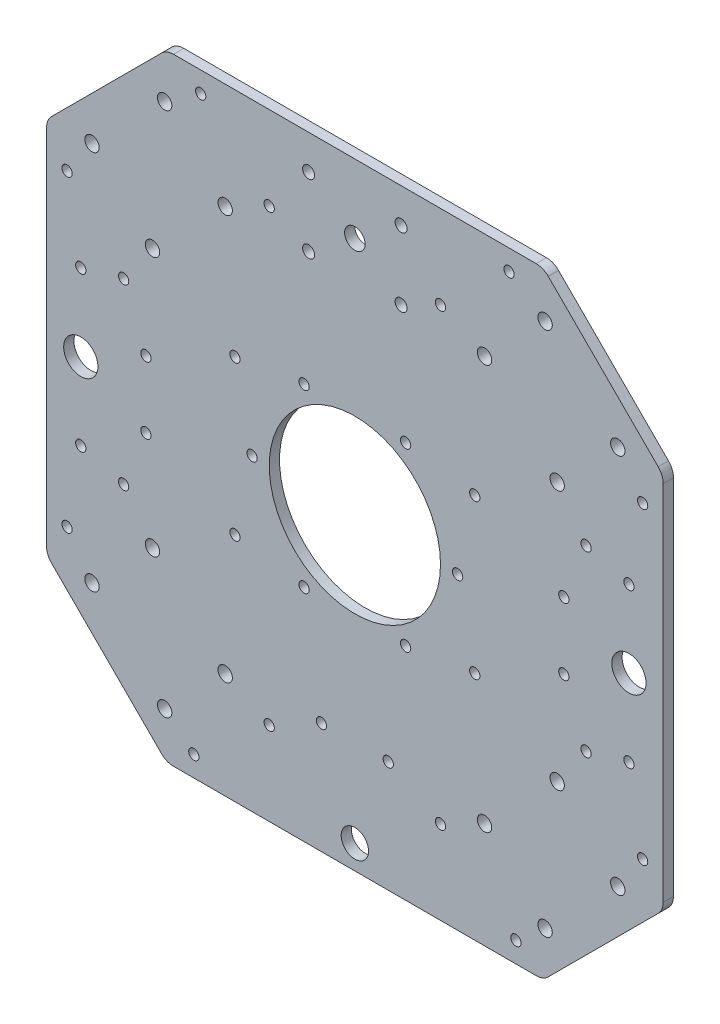
from build123d import *

# Parameters (mm, degrees)
SKETCH_1_W           = 180
SKETCH_1_H           = 180
EXTRUDE_1_DEPTH      = 3
CUT_EXTRUDE_1_DEPTH  = 3
SKETCH_3_R           = 2.1
CUT_EXTRUDE_2_DEPTH  = 3
SKETCH_4_R           = 25
SKETCH_4_R_2         = 1.5
CUT_EXTRUDE_3_DEPTH  = 3
SKETCH_5_R           = 1.5
SKETCH_5_R_2         = 5
CUT_EXTRUDE_4_DEPTH  = 3
SKETCH_6_R           = 1.5
CUT_EXTRUDE_5_DEPTH  = 3
FILLET_2_R           = 5
SKETCH_7_R           = 1.5
CUT_EXTRUDE_6_DEPTH  = 3
SKETCH_8_R           = 1.5
CUT_EXTRUDE_7_DEPTH  = 3
SKETCH_10_R          = 1.5
CUT_EXTRUDE_9_DEPTH  = 3
SKETCH_11_R          = 1.5
SKETCH_11_R_2        = 4
CUT_EXTRUDE_10_DEPTH = 3
SKETCH_12_R          = 3
CUT_EXTRUDE_11_DEPTH = 3
SKETCH_13_R          = 1.75
CUT_EXTRUDE_12_DEPTH = 3


with BuildPart() as part:
    # 草图1 → 凸台-拉伸1 (new body)
    with BuildSketch(Plane.XY):
        Rectangle(SKETCH_1_W, SKETCH_1_H)
    extrude(amount=EXTRUDE_1_DEPTH)

    # 草图2 → 切除-拉伸1 (cut)
    with BuildSketch(Plane.XY.offset(3)):
        Polygon((-90, 90), (-55, 90), (-90, 55), align=None)
        Polygon((90, 90), (55, 90), (90, 55), align=None)
        Polygon((-90, -90), (-90, -55), (-55, -90), align=None)
        Polygon((90, -90), (90, -55), (55, -90), align=None)
    extrude(amount=-CUT_EXTRUDE_1_DEPTH, mode=Mode.SUBTRACT)

    # 草图3 → 切除-拉伸2 (cut)
    with BuildSketch(Plane.XY.offset(3)):
        with Locations((55.529437252, 76.742640687)):
            Circle(SKETCH_3_R)
        with Locations((76.742640687, 55.529437252)):
            Circle(SKETCH_3_R)
        with Locations((59.064971157, 37.851767722)):
            Circle(SKETCH_3_R)
        with Locations((37.851767722, 59.064971157)):
            Circle(SKETCH_3_R)
        with Locations((-55.529437252, 76.742640687)):
            Circle(SKETCH_3_R)
        with Locations((-37.851767722, 59.064971157)):
            Circle(SKETCH_3_R)
        with Locations((-59.064971157, 37.851767722)):
            Circle(SKETCH_3_R)
        with Locations((-76.742640687, 55.529437252)):
            Circle(SKETCH_3_R)
        with Locations((-59.064971157, -37.851767722)):
            Circle(SKETCH_3_R)
        with Locations((-76.742640687, -55.529437252)):
            Circle(SKETCH_3_R)
        with Locations((-37.851767722, -59.064971157)):
            Circle(SKETCH_3_R)
        with Locations((-55.529437252, -76.742640687)):
            Circle(SKETCH_3_R)
        with Locations((76.742640687, -55.529437252)):
            Circle(SKETCH_3_R)
        with Locations((55.529437252, -76.742640687)):
            Circle(SKETCH_3_R)
        with Locations((37.851767722, -59.064971157)):
            Circle(SKETCH_3_R)
        with Locations((59.064971157, -37.851767722)):
            Circle(SKETCH_3_R)
    extrude(amount=-CUT_EXTRUDE_2_DEPTH, mode=Mode.SUBTRACT)

    # 草图4 → 切除-拉伸3 (cut)
    with BuildSketch(Plane.XY.offset(3)):
        Circle(SKETCH_4_R)
        with Locations((67.5, 26)):
            Circle(SKETCH_4_R_2)
        with Locations((67.5, -26)):
            Circle(SKETCH_4_R_2)
        with Locations((-67.5, -26)):
            Circle(SKETCH_4_R_2)
        with Locations((-67.5, 26)):
            Circle(SKETCH_4_R_2)
    extrude(amount=-CUT_EXTRUDE_3_DEPTH, mode=Mode.SUBTRACT)

    # 草图5 → 切除-拉伸4 (cut)
    with BuildSketch(Plane.XY.offset(3)):
        with Locations((61, 9.75)):
            Circle(SKETCH_5_R)
        with Locations((61, -9.75)):
            Circle(SKETCH_5_R)
        with Locations((80, 0)):
            Circle(SKETCH_5_R_2)
        with Locations((35, 22.5)):
            Circle(SKETCH_5_R)
        with Locations((35, -22.5)):
            Circle(SKETCH_5_R)
        with Locations((80, -22.5)):
            Circle(SKETCH_5_R)
        with Locations((80, 22.5)):
            Circle(SKETCH_5_R)
        with Locations((-80, 22.5)):
            Circle(SKETCH_5_R)
        with Locations((-80, -22.5)):
            Circle(SKETCH_5_R)
        with Locations((-35, -22.5)):
            Circle(SKETCH_5_R)
        with Locations((-35, 22.5)):
            Circle(SKETCH_5_R)
        with Locations((-61, 9.75)):
            Circle(SKETCH_5_R)
        with Locations((-61, -9.75)):
            Circle(SKETCH_5_R)
        with Locations((-80, 0)):
            Circle(SKETCH_5_R_2)
    extrude(amount=-CUT_EXTRUDE_4_DEPTH, mode=Mode.SUBTRACT)

    # 草图6 → 切除-拉伸5 (cut)
    with BuildSketch(Plane.XY.offset(3)):
        with Locations((14.820508076, 25.669872981)):
            Circle(SKETCH_6_R)
        with Locations((-14.820508076, 25.669872981)):
            Circle(SKETCH_6_R)
        with Locations((-30, 0)):
            Circle(SKETCH_6_R)
        with Locations((-14.820508076, -25.669872981)):
            Circle(SKETCH_6_R)
        with Locations((14.820508076, -25.669872981)):
            Circle(SKETCH_6_R)
        with Locations((30, 0)):
            Circle(SKETCH_6_R)
    extrude(amount=-CUT_EXTRUDE_5_DEPTH, mode=Mode.SUBTRACT)

    # 圆角2
    fillet_2_edges = [part.edges().sort_by_distance(p)[0] for p in [
        (90, 55, 1.5),
        (55, 90, 1.5),
        (-55, -90, 1.5),
        (-90, -55, 1.5),
        (55, -90, 1.5),
        (90, -55, 1.5),
        (-90, 55, 1.5),
        (-55, 90, 1.5),
    ]]
    fillet(fillet_2_edges, radius=FILLET_2_R)

    # 草图7 → 切除-拉伸6 (cut)
    with BuildSketch(Plane.XY.offset(3)):
        with Locations((-25, 65.6)):
            Circle(SKETCH_7_R)
        with Locations((25, 65.6)):
            Circle(SKETCH_7_R)
    extrude(amount=-CUT_EXTRUDE_6_DEPTH, mode=Mode.SUBTRACT)

    # 草图8 → 切除-拉伸7 (cut)
    with BuildSketch(Plane.XY.offset(3)):
        with Locations((25, -65.6)):
            Circle(SKETCH_8_R)
        with Locations((-25, -65.6)):
            Circle(SKETCH_8_R)
    extrude(amount=-CUT_EXTRUDE_7_DEPTH, mode=Mode.SUBTRACT)

    # 草图10 → 切除-拉伸9 (cut)
    with BuildSketch(Plane.XY.offset(3)):
        with Locations((-47, -84)):
            Circle(SKETCH_10_R)
        with Locations((47, -84)):
            Circle(SKETCH_10_R)
        with Locations((-84, -45)):
            Circle(SKETCH_10_R)
        with Locations((-84, 45)):
            Circle(SKETCH_10_R)
        with Locations((84, -45)):
            Circle(SKETCH_10_R)
        with Locations((84, 45)):
            Circle(SKETCH_10_R)
        with Locations((-45, 84)):
            Circle(SKETCH_10_R)
        with Locations((45, 84)):
            Circle(SKETCH_10_R)
    extrude(amount=-CUT_EXTRUDE_9_DEPTH, mode=Mode.SUBTRACT)

    # 草图11 → 切除-拉伸10 (cut)
    with BuildSketch(Plane.XY.offset(3)):
        with Locations((9.75, -57.5)):
            Circle(SKETCH_11_R)
        with Locations((-9.75, -57.5)):
            Circle(SKETCH_11_R)
        with Locations((0, -83)):
            Circle(SKETCH_11_R_2)
    extrude(amount=-CUT_EXTRUDE_10_DEPTH, mode=Mode.SUBTRACT)

    # 草图12 → 切除-拉伸11 (cut)
    with BuildSketch(Plane.XY.offset(3)):
        with Locations((0, 69.9)):
            Circle(SKETCH_12_R)
    extrude(amount=-CUT_EXTRUDE_11_DEPTH, mode=Mode.SUBTRACT)

    # 草图13 → 切除-拉伸12 (cut)
    with BuildSketch(Plane.XY.offset(3)):
        with Locations((-13.5, 79.940916293)):
            Circle(SKETCH_13_R)
        with Locations((-13.5, 59.859083707)):
            Circle(SKETCH_13_R)
        with Locations((13.5, 59.859083707)):
            Circle(SKETCH_13_R)
        with Locations((13.5, 79.940916293)):
            Circle(SKETCH_13_R)
    extrude(amount=-CUT_EXTRUDE_12_DEPTH, mode=Mode.SUBTRACT)


solid = part.part
